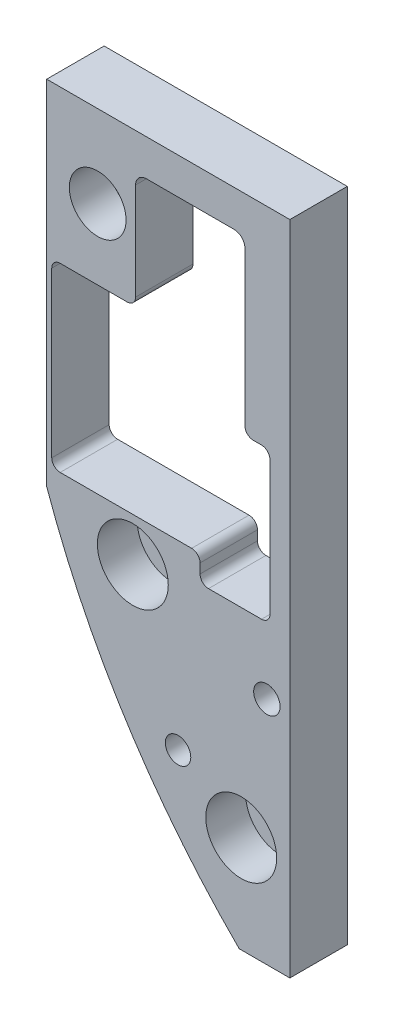
from build123d import *

# Parameters (mm, degrees)
SKETCH1_R           = 2.15265
SKETCH1_R_2         = 2.487009827
SKETCH1_R_3         = 2.39450721
BOSS_EXTRUDE1_DEPTH = 10.8
SKETCH3_R           = 6.6675
SKETCH3_R_2         = 5.334
CUT_EXTRUDE1_DEPTH  = 7.5


with BuildPart() as part:
    # Sketch1 → Boss-Extrude1 (new body)
    with BuildSketch(Plane.XY):
        with BuildLine():
            Line((0, -17.78), (-45.72, -17.78))
            Line((-45.72, -17.78), (-45.72, -84.1375))
            ThreePointArc((-45.72, -84.1375), (-30.833523511, -114.746148224), (-9.525, -141.2875))
            Line((-9.525, -141.2875), (0, -141.2875))
            Line((0, -141.2875), (0, -17.78))
        make_face()
        with Locations((-36.1315, -33.274)):
            Circle(SKETCH1_R, mode=Mode.SUBTRACT)
        with Locations((-29.5275, -88.7095)):
            Circle(SKETCH1_R, mode=Mode.SUBTRACT)
        with Locations((-9.144, -122.9995)):
            Circle(SKETCH1_R, mode=Mode.SUBTRACT)
        with Locations((-4.3173518, -98.035919174)):
            Circle(SKETCH1_R_2, mode=Mode.SUBTRACT)
        with Locations((-21.024674116, -114.680376144)):
            Circle(SKETCH1_R_3, mode=Mode.SUBTRACT)
        with BuildLine():
            Line((-30.5943, -46.501483685), (-43.185677441, -46.501483685))
            ThreePointArc((-43.185677441, -46.501483685), (-44.308209457, -46.96645167), (-44.773177441, -48.088983685))
            Line((-44.773177441, -48.088983685), (-44.773177441, -78.965225138))
            ThreePointArc((-44.773177441, -78.965225138), (-44.308209457, -80.087757153), (-43.185677441, -80.552725138))
            Line((-43.185677441, -80.552725138), (-18.474223541, -80.552725138))
            ThreePointArc((-18.474223541, -80.552725138), (-17.351691526, -81.017693123), (-16.886723541, -82.140225138))
            Line((-16.886723541, -82.140225138), (-16.886723541, -83.937143103))
            ThreePointArc((-16.886723541, -83.937143103), (-16.421755557, -85.059675118), (-15.299223541, -85.524643103))
            Line((-15.299223541, -85.524643103), (-5.327492268, -85.524643103))
            ThreePointArc((-5.327492268, -85.524643103), (-4.204960252, -85.059675118), (-3.739992268, -83.937143103))
            Line((-3.739992268, -83.937143103), (-3.739992268, -58.7502))
            ThreePointArc((-3.739992268, -58.7502), (-4.204960252, -57.627667985), (-5.327492268, -57.1627))
            Line((-5.327492268, -57.1627), (-6.8707, -57.1627))
            ThreePointArc((-6.8707, -57.1627), (-7.993232015, -56.697732015), (-8.4582, -55.5752))
            Line((-8.4582, -55.5752), (-8.4582, -26.6573))
            ThreePointArc((-8.4582, -26.6573), (-9.053359021, -25.220459021), (-10.4902, -24.6253))
            Line((-10.4902, -24.6253), (-26.9748, -24.6253))
            ThreePointArc((-26.9748, -24.6253), (-28.411640979, -25.220459021), (-29.0068, -26.6573))
            Line((-29.0068, -26.6573), (-29.0068, -44.913983685))
            ThreePointArc((-29.0068, -44.913983685), (-29.471767985, -46.036515701), (-30.5943, -46.501483685))
        make_face(mode=Mode.SUBTRACT)
    extrude(amount=BOSS_EXTRUDE1_DEPTH)

    # Sketch3 → Cut-Extrude1 (cut)
    with BuildSketch(Plane.XY.offset(10.8)):
        with Locations((-9.144, -122.9995)):
            Circle(SKETCH3_R)
        with Locations((-29.5275, -88.7095)):
            Circle(SKETCH3_R)
        with Locations((-36.1315, -33.274)):
            Circle(SKETCH3_R_2)
    extrude(amount=-CUT_EXTRUDE1_DEPTH, mode=Mode.SUBTRACT)


solid = part.part
